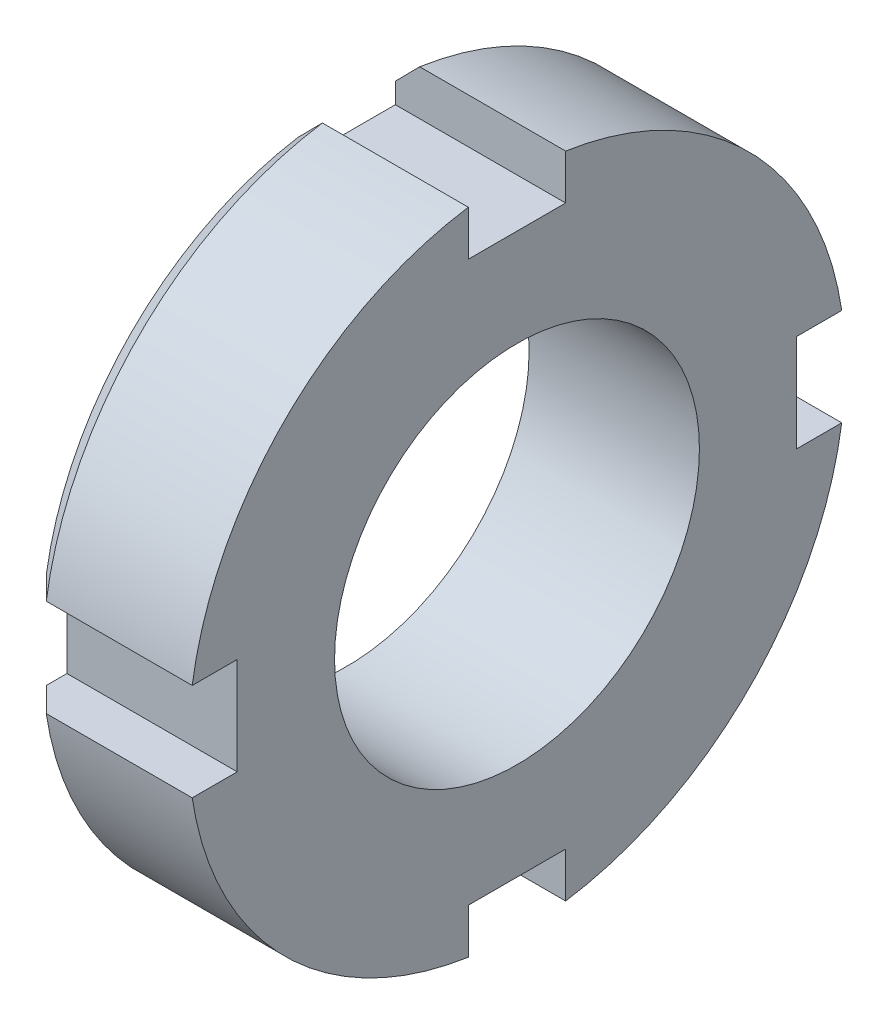
from build123d import *

# Parameters (mm, degrees)
SKETCH1_R           = 13.5
BOSS_EXTRUDE1_DEPTH = 7
SKETCH2_R           = 7.5
CUT_EXTRUDE1_DEPTH  = 8
CHAMFER1_SIZE       = 1
SKETCH3_W           = 4
SKETCH3_H           = 4
CUT_EXTRUDE2_DEPTH  = 8
CIRPATTERN1_COUNT   = 4


with BuildPart() as part:
    # Sketch1 → Boss-Extrude1 (new body)
    with BuildSketch(Plane(origin=(0, 0, 0), x_dir=(0, 0, -1), z_dir=(1, 0, 0))):
        Circle(SKETCH1_R)
    extrude(amount=BOSS_EXTRUDE1_DEPTH)

    # Sketch2 → Cut-Extrude1 (cut, through all)
    with BuildSketch(Plane(origin=(7, 0, 0), x_dir=(0, 0, -1), z_dir=(1, 0, 0))):
        Circle(SKETCH2_R)
    extrude(amount=-CUT_EXTRUDE1_DEPTH, mode=Mode.SUBTRACT)

    # Chamfer1
    chamfer1_edges = [part.edges().sort_by_distance(p)[0] for p in [
        (0, 0, 13.5),
    ]]
    chamfer(chamfer1_edges, length=CHAMFER1_SIZE)

    # Sketch3 → Cut-Extrude2 (cut, through all)
    with BuildSketch(Plane(origin=(7, 0, 0), x_dir=(0, 0, -1), z_dir=(1, 0, 0))):
        with Locations((0, 13.5)):
            Rectangle(SKETCH3_W, SKETCH3_H)
    cut_extrude2 = extrude(amount=-CUT_EXTRUDE2_DEPTH, mode=Mode.SUBTRACT)

    # CirPattern1: Cut-Extrude2 ×4 about axis
    cirpattern1_axis = Axis((0, 0, 0), (1, 0, 0))
    for i in range(1, CIRPATTERN1_COUNT):
        add(cut_extrude2.rotate(cirpattern1_axis, i * 360 / CIRPATTERN1_COUNT), mode=Mode.SUBTRACT)


solid = part.part
